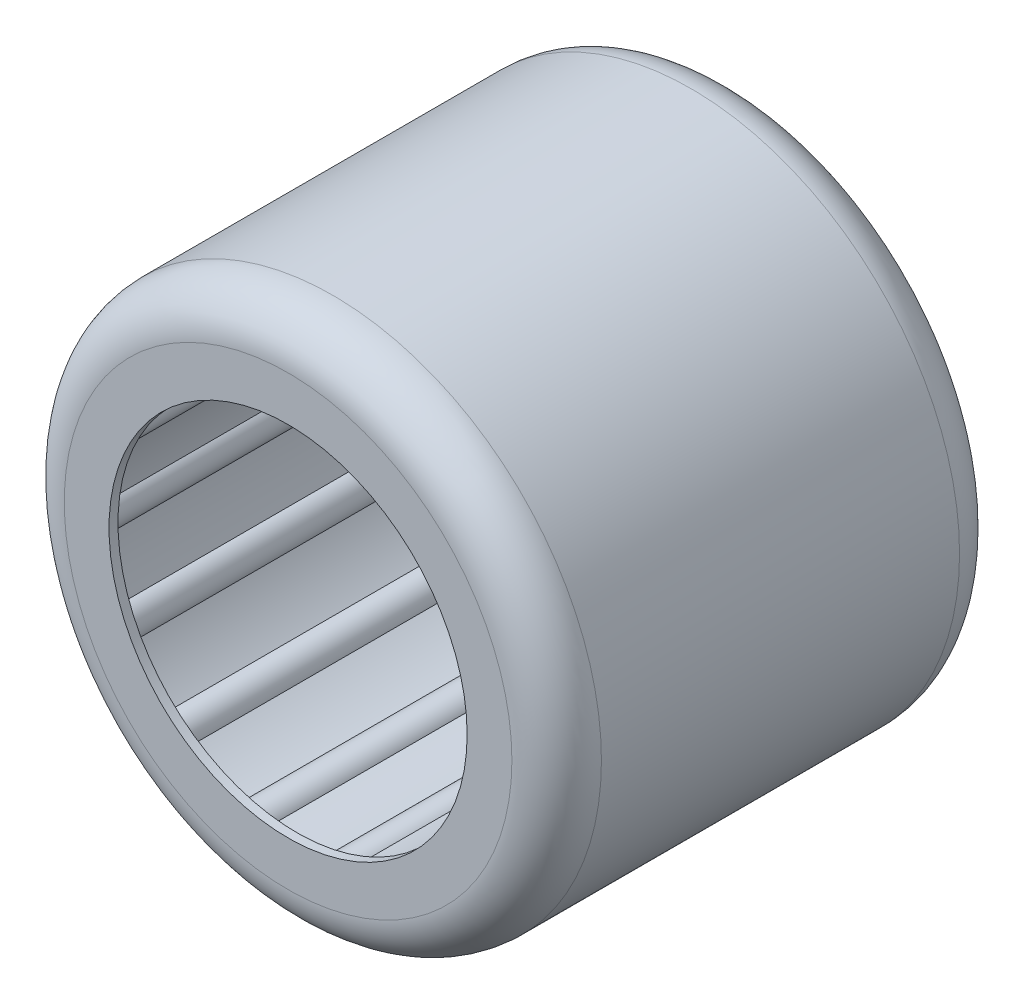
from build123d import *

# Parameters (mm, degrees)
ESQUISSE1_R             = 6
BOSS_EXTRU_2_DEPTH      = 10
CONG_2_R                = 1
ESQUISSE5_R             = 4
ENL_V_MAT_EXTRU_2_DEPTH = 14.114877094
COQUE5_T                = -0.2
BOSS_EXTRU_5_REACH      = 14.963


with BuildPart() as part:
    # Esquisse1 → Boss.-Extru.2 (new body)
    with BuildSketch(Plane.XY):
        Circle(ESQUISSE1_R)
    extrude(amount=BOSS_EXTRU_2_DEPTH)

    # Congé2
    cong_2_edges = [part.edges().sort_by_distance(p)[0] for p in [
        (-6, 0, 0),
        (-6, 0, 10),
    ]]
    fillet(cong_2_edges, radius=CONG_2_R)

    # Esquisse5 → Enlèv. mat.-Extru.2 (cut, through all)
    with BuildSketch(Plane.XY.offset(10)):
        Circle(ESQUISSE5_R)
    extrude(amount=-ENL_V_MAT_EXTRU_2_DEPTH, mode=Mode.SUBTRACT)

    # Coque5
    coque5_openings = [part.faces().sort_by_distance(p)[0] for p in [
        (-4, 0, 5),
    ]]
    offset(amount=COQUE5_T, openings=coque5_openings, kind=Kind.INTERSECTION)

    # Esquisse12 → Boss.-Extru.5 (add, up to next)
    with BuildSketch(Plane.XY.offset(0.2), mode=Mode.PRIVATE) as boss_extru_5_sk1:
        with BuildLine():
            ThreePointArc((-4.089017574, 1.521224294), (-4.253433845, 0.970818519), (-4.344112019, 0.403582504))
            ThreePointArc((-4.344112019, 0.403582504), (-4.932642925, 0), (-4.344112019, -0.403582504))
            ThreePointArc((-4.344112019, -0.403582504), (-4.253433845, -0.970818519), (-4.089017574, -1.521224294))
            ThreePointArc((-4.089017574, -1.521224294), (-4.444157712, -2.140193556), (-3.738801802, -2.248454838))
            ThreePointArc((-3.738801802, -2.248454838), (-3.410989107, -2.720173043), (-3.02404305, -3.144733964))
            ThreePointArc((-3.02404305, -3.144733964), (-3.07545256, -3.85649553), (-2.392976034, -3.647993115))
            ThreePointArc((-2.392976034, -3.647993115), (-1.892956143, -3.930763935), (-1.360119712, -4.145390505))
            ThreePointArc((-1.360119712, -4.145390505), (-1.097616311, -4.808971268), (-0.573192015, -4.325001617))
            ThreePointArc((-0.573192015, -4.325001617), (0, -4.362818822), (0.573192015, -4.325001617))
            ThreePointArc((0.573192015, -4.325001617), (1.097616311, -4.808971268), (1.360119712, -4.145390505))
            ThreePointArc((1.360119712, -4.145390505), (1.892956143, -3.930763935), (2.392976034, -3.647993115))
            ThreePointArc((2.392976034, -3.647993115), (3.07545256, -3.85649553), (3.02404305, -3.144733964))
            ThreePointArc((3.02404305, -3.144733964), (3.410989107, -2.720173043), (3.738801802, -2.248454838))
            ThreePointArc((3.738801802, -2.248454838), (4.444157712, -2.140193556), (4.089017574, -1.521224294))
            ThreePointArc((4.089017574, -1.521224294), (4.253433845, -0.970818519), (4.344112019, -0.403582504))
            ThreePointArc((4.344112019, -0.403582504), (4.932642925, 0), (4.344112019, 0.403582504))
            ThreePointArc((4.344112019, 0.403582504), (4.253433845, 0.970818519), (4.089017574, 1.521224294))
            ThreePointArc((4.089017574, 1.521224294), (4.444157712, 2.140193556), (3.738801802, 2.248454838))
            ThreePointArc((3.738801802, 2.248454838), (3.410989107, 2.720173043), (3.02404305, 3.144733964))
            ThreePointArc((3.02404305, 3.144733964), (3.07545256, 3.85649553), (2.392976034, 3.647993115))
            ThreePointArc((2.392976034, 3.647993115), (1.892956143, 3.930763935), (1.360119712, 4.145390505))
            ThreePointArc((1.360119712, 4.145390505), (1.097616311, 4.808971268), (0.573192015, 4.325001617))
            ThreePointArc((0.573192015, 4.325001617), (0, 4.362818822), (-0.573192015, 4.325001617))
            ThreePointArc((-0.573192015, 4.325001617), (-1.097616311, 4.808971268), (-1.360119712, 4.145390505))
            ThreePointArc((-1.360119712, 4.145390505), (-1.892956143, 3.930763935), (-2.392976034, 3.647993115))
            ThreePointArc((-2.392976034, 3.647993115), (-3.07545256, 3.85649553), (-3.02404305, 3.144733964))
            ThreePointArc((-3.02404305, 3.144733964), (-3.410989107, 2.720173043), (-3.738801802, 2.248454838))
            ThreePointArc((-3.738801802, 2.248454838), (-4.444157712, 2.140193556), (-4.089017574, 1.521224294))
        make_face()
        with BuildLine():
            ThreePointArc((-3.940916918, 1.53497163), (-4.123260956, 0.941107406), (-4.216642684, 0.326938116))
            ThreePointArc((-4.216642684, 0.326938116), (-4.067357075, 0), (-4.216642684, -0.326938116))
            ThreePointArc((-4.216642684, -0.326938116), (-4.123260956, -0.941107406), (-3.940916918, -1.53497163))
            ThreePointArc((-3.940916918, -1.53497163), (-3.664562099, -1.764760096), (-3.657210653, -2.124093759))
            ThreePointArc((-3.657210653, -2.124093759), (-3.306598555, -2.636924355), (-2.884644224, -3.092861419))
            ThreePointArc((-2.884644224, -3.092861419), (-2.535955657, -3.179987812), (-2.373423199, -3.500546582))
            ThreePointArc((-2.373423199, -3.500546582), (-1.835023758, -3.810466096), (-1.257032364, -4.038172073))
            ThreePointArc((-1.257032364, -4.038172073), (-0.905072095, -3.965379941), (-0.619550173, -4.183673224))
            ThreePointArc((-0.619550173, -4.183673224), (0, -4.229298294), (0.619550173, -4.183673224))
            ThreePointArc((0.619550173, -4.183673224), (0.905072095, -3.965379941), (1.257032364, -4.038172073))
            ThreePointArc((1.257032364, -4.038172073), (1.835023758, -3.810466096), (2.373423199, -3.500546582))
            ThreePointArc((2.373423199, -3.500546582), (2.535955657, -3.179987812), (2.884644224, -3.092861419))
            ThreePointArc((2.884644224, -3.092861419), (3.306598555, -2.636924355), (3.657210653, -2.124093759))
            ThreePointArc((3.657210653, -2.124093759), (3.664562099, -1.764760096), (3.940916918, -1.53497163))
            ThreePointArc((3.940916918, -1.53497163), (4.123260956, -0.941107406), (4.216642684, -0.326938116))
            ThreePointArc((4.216642684, -0.326938116), (4.067357075, 0), (4.216642684, 0.326938116))
            ThreePointArc((4.216642684, 0.326938116), (4.123260956, 0.941107406), (3.940916918, 1.53497163))
            ThreePointArc((3.940916918, 1.53497163), (3.664562099, 1.764760096), (3.657210653, 2.124093759))
            ThreePointArc((3.657210653, 2.124093759), (3.306598555, 2.636924355), (2.884644224, 3.092861419))
            ThreePointArc((2.884644224, 3.092861419), (2.535955657, 3.179987812), (2.373423199, 3.500546582))
            ThreePointArc((2.373423199, 3.500546582), (1.835023758, 3.810466096), (1.257032364, 4.038172073))
            ThreePointArc((1.257032364, 4.038172073), (0.905072095, 3.965379941), (0.619550173, 4.183673224))
            ThreePointArc((0.619550173, 4.183673224), (0, 4.229298294), (-0.619550173, 4.183673224))
            ThreePointArc((-0.619550173, 4.183673224), (-0.905072095, 3.965379941), (-1.257032364, 4.038172073))
            ThreePointArc((-1.257032364, 4.038172073), (-1.835023758, 3.810466096), (-2.373423199, 3.500546582))
            ThreePointArc((-2.373423199, 3.500546582), (-2.535955657, 3.179987812), (-2.884644224, 3.092861419))
            ThreePointArc((-2.884644224, 3.092861419), (-3.306598555, 2.636924355), (-3.657210653, 2.124093759))
            ThreePointArc((-3.657210653, 2.124093759), (-3.664562099, 1.764760096), (-3.940916918, 1.53497163))
        make_face(mode=Mode.SUBTRACT)
    boss_extru_5_tool1 = extrude(boss_extru_5_sk1.sketch, amount=BOSS_EXTRU_5_REACH, mode=Mode.PRIVATE) - part.part
    add(boss_extru_5_tool1.solids().sort_by_distance((-3.400205, 2.711573, 0.2))[0])


solid = part.part
